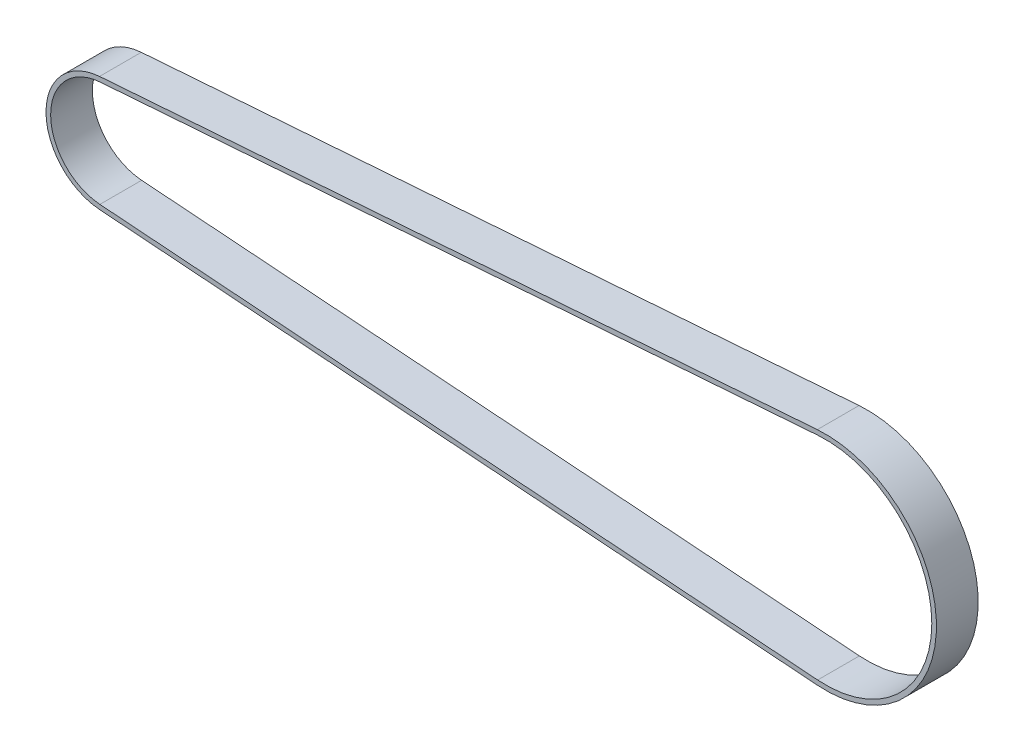
from build123d import *

# Parameters (mm, degrees)
BOSS_EXTRUDE2_DEPTH = 9


with BuildPart() as part:
    # Sketch1 → Boss-Extrude2 (new body)
    with BuildSketch(Plane.XY):
        with BuildLine():
            Line((76.027182512, -23.853343612), (-78.706582076, -12.425313679))
            ThreePointArc((-78.706582076, -12.425313679), (-90.248052967, 0), (-78.706582076, 12.425313679))
            Line((-78.706582076, 12.425313679), (76.027182512, 23.853343612))
            ThreePointArc((76.027182512, 23.853343612), (101.707208869, 0), (76.027182512, -23.853343612))
        make_face()
        with BuildLine():
            Line((76.100837984, -22.856059865), (-78.632926604, -11.428029932))
            ThreePointArc((-78.632926604, -11.428029932), (-89.248052967, 0), (-78.632926604, 11.428029932))
            Line((-78.632926604, 11.428029932), (76.100837984, 22.856059865))
            ThreePointArc((76.100837984, 22.856059865), (100.707208869, 0), (76.100837984, -22.856059865))
        make_face(mode=Mode.SUBTRACT)
    extrude(amount=BOSS_EXTRUDE2_DEPTH)


solid = part.part
